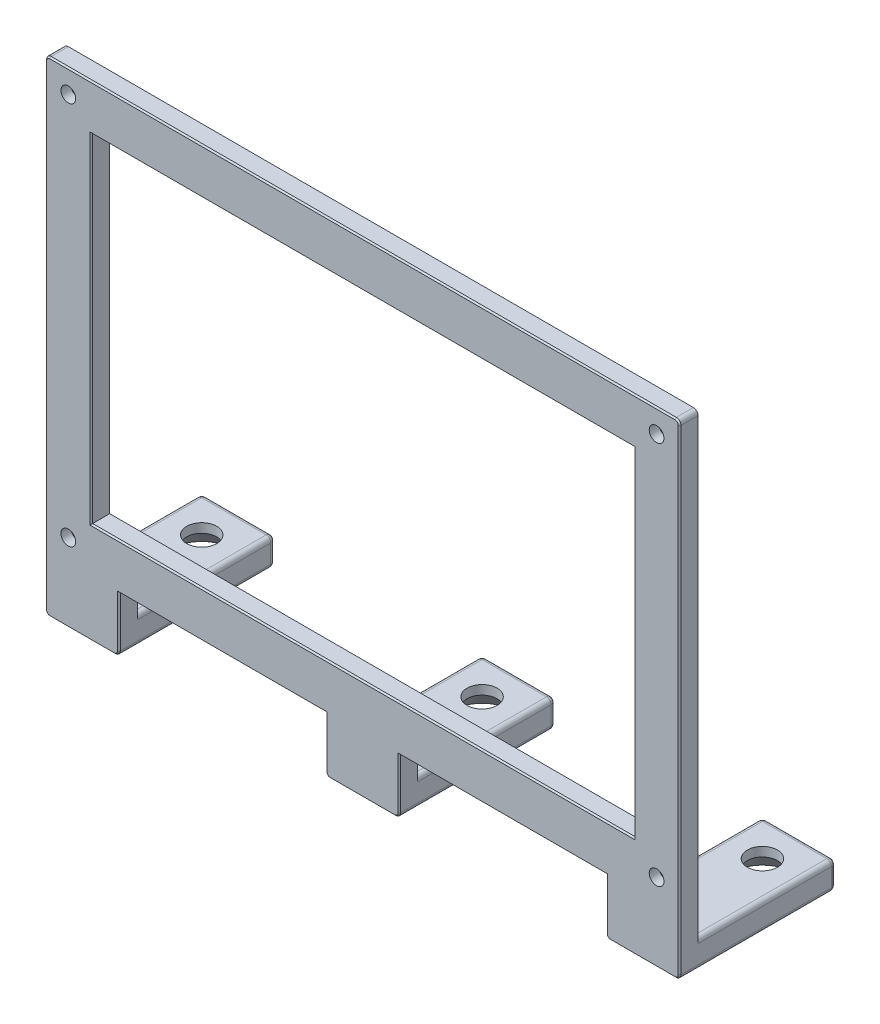
from build123d import *

# Parameters (mm, degrees)
SKETCH1_W                                           = 117.86
SKETCH1_H                                           = 73.41
SKETCH1_R                                           = 1.6
BOSS_EXTRUDE1_DEPTH                                 = 4
SKETCH1_3_W                                         = 16
SKETCH1_3_H                                         = 6
BOSS_EXTRUDE2_DEPTH                                 = 30
CUT_EXTRUDE1_REACH                                  = 131.471
SKETCH2_R                                           = 3.2639
CSK_FOR_1_4_FLAT_HEAD_SOCKET_CAP_SCREW1_D           = 6.5278
CSK_FOR_1_4_FLAT_HEAD_SOCKET_CAP_SCREW1_CSINK_D     = 13.4874
CSK_FOR_1_4_FLAT_HEAD_SOCKET_CAP_SCREW1_CSINK_ANGLE = 82
FILLET1_R                                           = 1
CSK_FOR_M3_SFHCS1_D                                 = 3.2
CSK_FOR_M3_SFHCS1_CSINK_D                           = 6.92
CSK_FOR_M3_SFHCS1_CSINK_ANGLE                       = 90
CHAMFER1_SIZE                                       = 0.3


with BuildPart() as part:
    # Sketch1 → Boss-Extrude1 (new body)
    with BuildSketch(Plane.XY):
        Polygon((-68.93, 45.21), (-68.93, -60.2), (-52.93, -60.2), (-52.93, -48.2), (-8, -48.2), (-8, -60.2), (8, -60.2), (8, -48.2), (52.93, -48.2), (52.93, -60.2), (68.93, -60.2), (68.93, 45.21), align=None)
        with Locations((0, -1.495)):
            Rectangle(SKETCH1_W, SKETCH1_H, mode=Mode.SUBTRACT)
        with Locations((63.93, 40.21)):
            Circle(SKETCH1_R, mode=Mode.SUBTRACT)
        with Locations((63.93, -43.2)):
            Circle(SKETCH1_R, mode=Mode.SUBTRACT)
        with Locations((-63.93, 40.21)):
            Circle(SKETCH1_R, mode=Mode.SUBTRACT)
        with Locations((-63.93, -43.2)):
            Circle(SKETCH1_R, mode=Mode.SUBTRACT)
    extrude(amount=BOSS_EXTRUDE1_DEPTH)

    # Sketch1_3 → Boss-Extrude2 (add)
    with BuildSketch(Plane.XY):
        with Locations((-60.93, -57.2)):
            Rectangle(SKETCH1_3_W, SKETCH1_3_H)
        with Locations((60.93, -57.2)):
            Rectangle(SKETCH1_3_W, SKETCH1_3_H)
        with Locations((0, -57.2)):
            Rectangle(SKETCH1_3_W, SKETCH1_3_H)
    extrude(amount=-BOSS_EXTRUDE2_DEPTH)

    # Sketch2 → Cut-Extrude1 (cut, up to next)
    with BuildSketch(Plane.XZ.offset(60.2), mode=Mode.PRIVATE) as cut_extrude1_sk1:
        with Locations((-60.93, -22)):
            Circle(SKETCH2_R)
    cut_extrude1_tool1 = extrude(cut_extrude1_sk1.sketch, amount=-CUT_EXTRUDE1_REACH, mode=Mode.PRIVATE) & part.part
    # Sketch2 → Cut-Extrude1 (cut, up to next)
    with BuildSketch(Plane.XZ.offset(60.2), mode=Mode.PRIVATE) as cut_extrude1_sk2:
        with Locations((0, -22)):
            Circle(SKETCH2_R)
    cut_extrude1_tool2 = extrude(cut_extrude1_sk2.sketch, amount=-CUT_EXTRUDE1_REACH, mode=Mode.PRIVATE) & part.part
    # Sketch2 → Cut-Extrude1 (cut, up to next)
    with BuildSketch(Plane.XZ.offset(60.2), mode=Mode.PRIVATE) as cut_extrude1_sk3:
        with Locations((60.93, -22)):
            Circle(SKETCH2_R)
    cut_extrude1_tool3 = extrude(cut_extrude1_sk3.sketch, amount=-CUT_EXTRUDE1_REACH, mode=Mode.PRIVATE) & part.part
    add(cut_extrude1_tool1.solids().sort_by_distance((-60.93, -60.2, -22))[0], mode=Mode.SUBTRACT)
    add(cut_extrude1_tool2.solids().sort_by_distance((0, -60.2, -22))[0], mode=Mode.SUBTRACT)
    add(cut_extrude1_tool3.solids().sort_by_distance((60.93, -60.2, -22))[0], mode=Mode.SUBTRACT)

    # CSK for 1_4 Flat Head Socket Cap Screw1 (through all)
    with Locations(Plane(origin=(0, -60.2, 0), x_dir=(-1, 0, 0), z_dir=(0, -1, 0))):
        with Locations((60.93, 22), (0, 22), (-60.93, 22)):
            CounterSinkHole(CSK_FOR_1_4_FLAT_HEAD_SOCKET_CAP_SCREW1_D / 2, CSK_FOR_1_4_FLAT_HEAD_SOCKET_CAP_SCREW1_CSINK_D / 2, counter_sink_angle=CSK_FOR_1_4_FLAT_HEAD_SOCKET_CAP_SCREW1_CSINK_ANGLE)

    # Fillet1
    fillet1_edges = [part.edges().sort_by_distance(p)[0] for p in [
        (-60.93, -54.2, -30),
        (-68.93, -57.2, -30),
        (-60.93, -60.2, -30),
        (-52.93, -57.2, -30),
        (-8, -57.2, -30),
        (0, -60.2, -30),
        (8, -57.2, -30),
        (0, -54.2, -30),
        (52.93, -57.2, -30),
        (60.93, -60.2, -30),
        (68.93, -57.2, -30),
        (60.93, -54.2, -30),
        (52.93, -54.2, -15),
        (-8, -54.2, -15),
        (-68.93, -54.2, -15),
        (-52.93, -54.2, -15),
        (8, -54.2, -15),
        (68.93, -54.2, -15),
        (68.93, -60.2, -13),
        (52.93, -60.2, -13),
        (8, -60.2, -13),
        (-8, -60.2, -13),
        (-68.93, -60.2, -13),
        (-52.93, -60.2, -13),
        (-68.93, 45.21, 2),
        (68.93, 45.21, 2),
    ]]
    fillet(fillet1_edges, radius=FILLET1_R)

    # CSK for M3 SFHCS1 (through all)
    with Locations(Plane(origin=(0, 0, 0), x_dir=(-1, 0, 0), z_dir=(0, 0, -1))):
        with Locations((63.93, 40.21), (63.93, -43.2), (-63.93, -43.2), (-63.93, 40.21)):
            CounterSinkHole(CSK_FOR_M3_SFHCS1_D / 2, CSK_FOR_M3_SFHCS1_CSINK_D / 2, counter_sink_angle=CSK_FOR_M3_SFHCS1_CSINK_ANGLE)

    # Chamfer1
    chamfer1_edges = [part.edges().sort_by_distance(p)[0] for p in [
        (0, -38.2, 4),
        (58.93, -1.495, 4),
        (-58.93, -1.495, 4),
        (0, 35.21, 4),
        (-8, -53.7, 4),
        (8, -53.7, 4),
        (-7.707106781, -59.907106781, 4),
        (7.707106781, -59.907106781, 4),
        (0, -60.2, 4),
        (30.465, -48.2, 4),
        (-30.465, -48.2, 4),
        (52.93, -53.7, 4),
        (53.222893219, -59.907106781, 4),
        (60.93, -60.2, 4),
        (68.637106781, -59.907106781, 4),
        (68.93, -7.495, 4),
        (68.637106781, 44.917106781, 4),
        (0, 45.21, 4),
        (-68.637106781, 44.917106781, 4),
        (-68.93, -7.495, 4),
        (-52.93, -53.7, 4),
        (-68.637106781, -59.907106781, 4),
        (-53.222893219, -59.907106781, 4),
        (-60.93, -60.2, 4),
    ]]
    chamfer(chamfer1_edges, length=CHAMFER1_SIZE)


solid = part.part
